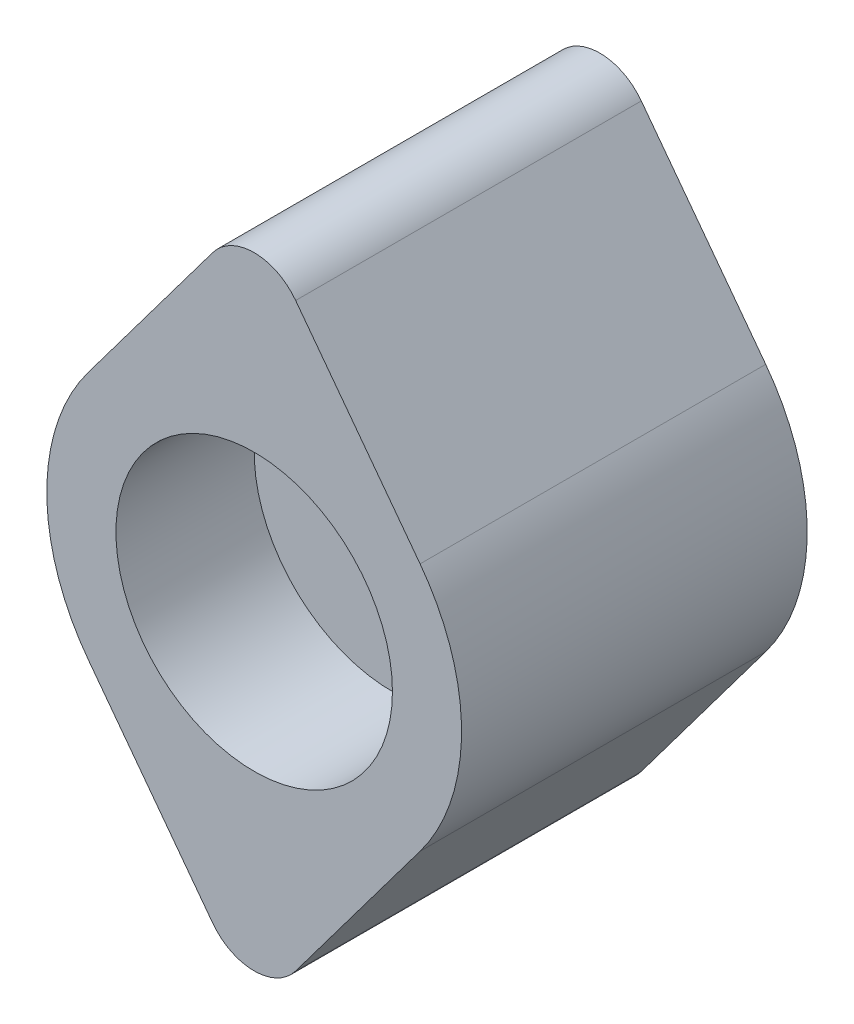
from build123d import *

# Parameters (mm, degrees)
EXTRUDE_1_DEPTH     = 10
SKETCH_2_R          = 4
CUT_EXTRUDE_1_DEPTH = 4
M4X0_71_D           = 3.3
FILLET_1_R          = 1.5


with BuildPart() as part:
    # Эскиз1 → Бобышка-Вытянуть1 (new body)
    with BuildSketch(Plane.XY):
        with BuildLine():
            Line((0, 10), (-4.8, 3.6))
            ThreePointArc((-4.8, 3.6), (-6, 0), (-4.8, -3.6))
            Line((-4.8, -3.6), (0, -10))
            Line((0, -10), (4.8, -3.6))
            ThreePointArc((4.8, -3.6), (6, 0), (4.8, 3.6))
            Line((4.8, 3.6), (0, 10))
        make_face()
    extrude(amount=EXTRUDE_1_DEPTH)

    # Эскиз2 → Вырез-Вытянуть1 (cut)
    with BuildSketch(Plane.XY.offset(10)):
        Circle(SKETCH_2_R)
    extrude(amount=-CUT_EXTRUDE_1_DEPTH, mode=Mode.SUBTRACT)

    # Отверстие обработанное метчиком M4x0.71 (through all)
    with Locations(Plane.XY.offset(6)):
        with Locations((0, 0)):
            Hole(M4X0_71_D / 2)

    # Скругление1
    fillet_1_edges = [part.edges().sort_by_distance(p)[0] for p in [
        (0, -10, 5),
        (0, 10, 5),
    ]]
    fillet(fillet_1_edges, radius=FILLET_1_R)


solid = part.part
